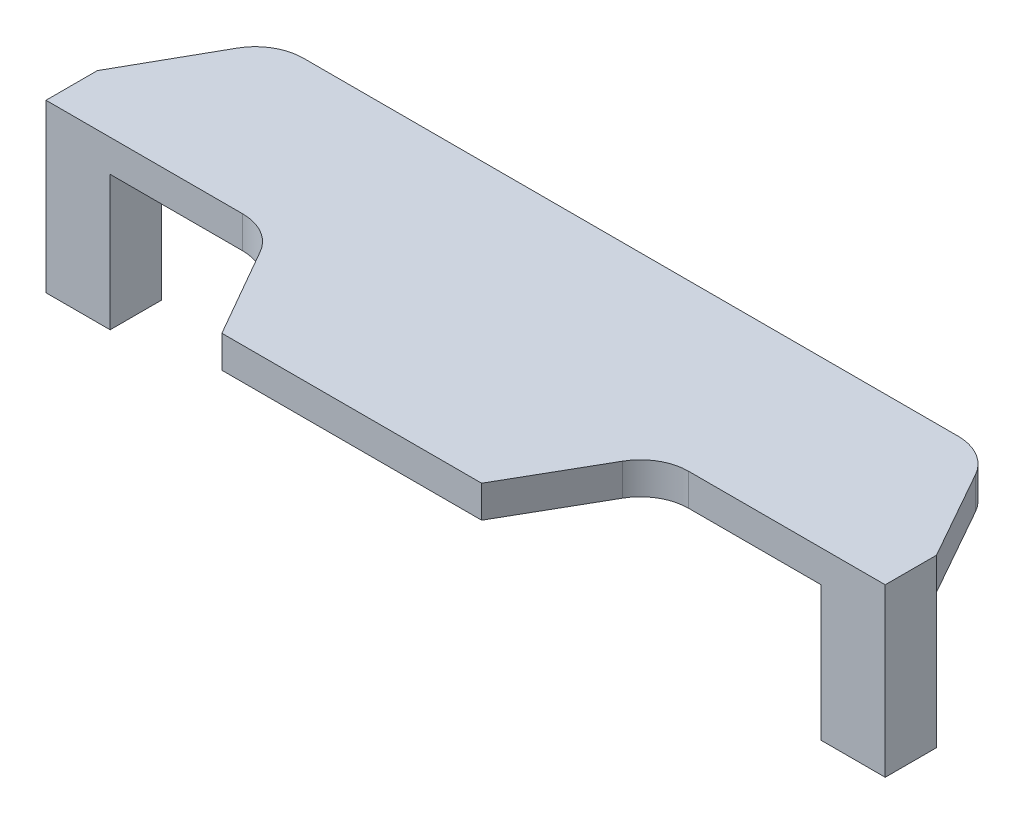
from build123d import *

# Parameters (mm, degrees)
SKETCH1_W             = 10
SKETCH1_H             = 8
BOSS_EXTRUDE1_DEPTH   = 21
BOSS_EXTRUDE1_2_DEPTH = 21
BOSS_EXTRUDE2_DEPTH   = 5


with BuildPart() as part:
    # Sketch1 → Boss-Extrude1 (new body)
    with BuildSketch(Plane(origin=(0, 0, 0), x_dir=(1, 0, 0), z_dir=(0, 1, 0))):
        with Locations((-60.425, 0)):
            Rectangle(SKETCH1_W, SKETCH1_H)
    extrude(amount=BOSS_EXTRUDE1_DEPTH)



with BuildPart() as body_2:
    # Sketch1 → Boss-Extrude1 2 (new body)
    with BuildSketch(Plane(origin=(0, 0, 0), x_dir=(1, 0, 0), z_dir=(0, 1, 0))):
        with Locations((60.425, 0)):
            Rectangle(SKETCH1_W, SKETCH1_H)
    extrude(amount=BOSS_EXTRUDE1_2_DEPTH)


with BuildPart() as part_1:
    add(part.part)

    add(body_2.part)  # Boss-Extrude2 merges body 2
    # Sketch2 → Boss-Extrude2 (add)
    with BuildSketch(Plane(origin=(0, 21, 0), x_dir=(1, 0, 0), z_dir=(0, 1, 0))):
        with BuildLine():
            Line((-21.75, 21.75), (21.75, 21.75))
            Line((21.75, 21.75), (51.042007296, 21.75))
            ThreePointArc((51.042007296, 21.75), (54.826187522, 20.725336286), (57.576364504, 17.931328005))
            Line((57.576364504, 17.931328005), (65.425, 4))
            Line((65.425, 4), (65.425, -4))
            Line((65.425, -4), (34.770583875, -4))
            ThreePointArc((34.770583875, -4), (31.010557787, -5.010608363), (28.263842049, -7.770078981))
            Line((28.263842049, -7.770078981), (20.25, -21.75))
            Line((20.25, -21.75), (-20.25, -21.75))
            Line((-20.25, -21.75), (-28.263842049, -7.770078981))
            ThreePointArc((-28.263842049, -7.770078981), (-31.010557787, -5.010608363), (-34.770583875, -4))
            Line((-34.770583875, -4), (-65.425, -4))
            Line((-65.425, -4), (-65.425, 4))
            Line((-65.425, 4), (-57.576364504, 17.931328005))
            ThreePointArc((-57.576364504, 17.931328005), (-54.826187522, 20.725336286), (-51.042007296, 21.75))
            Line((-51.042007296, 21.75), (-21.75, 21.75))
        make_face()
    extrude(amount=BOSS_EXTRUDE2_DEPTH)


solid = part_1.part
